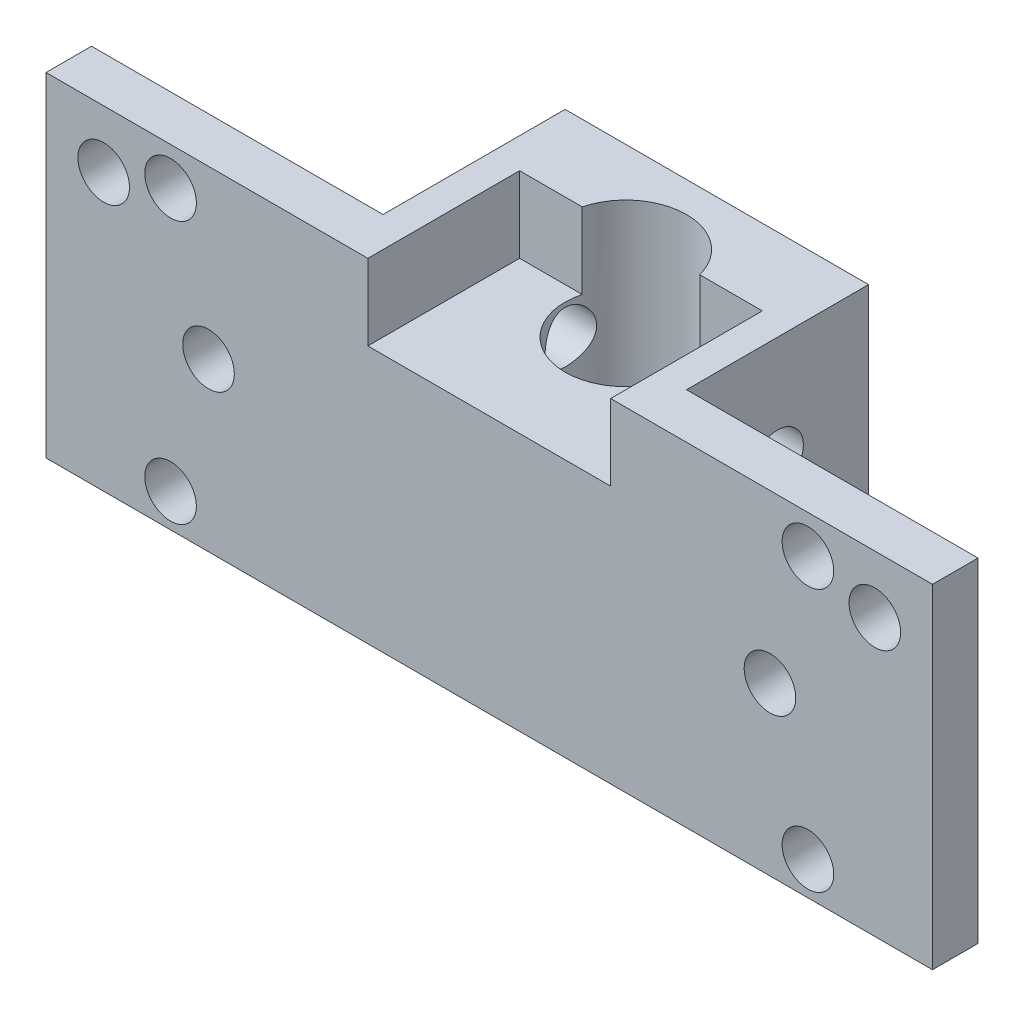
from build123d import *

# Parameters (mm, degrees)
ESQUISSE1_W             = 20
ESQUISSE1_H             = 22
BOSS_EXTRU_1_DEPTH      = 12
ESQUISSE2_R             = 4
ENL_V_MAT_EXTRU_1_DEPTH = 26
ESQUISSE4_W             = 58.42
ESQUISSE4_H             = 22
ESQUISSE4_R             = 1.7
BOSS_EXTRU_2_DEPTH      = 3
ESQUISSE5_R             = 1.7
ENL_V_MAT_EXTRU_2_DEPTH = 3
ESQUISSE3_R             = 1.7
ENL_V_MAT_EXTRU_3_DEPTH = 27
ESQUISSE6_W             = 16
ESQUISSE6_H             = 5
ENL_V_MAT_EXTRU_4_DEPTH = 10


with BuildPart() as part:
    # Esquisse1 → Boss.-Extru.1 (new body)
    with BuildSketch(Plane.XY):
        with Locations((10, 11)):
            Rectangle(ESQUISSE1_W, ESQUISSE1_H)
    extrude(amount=BOSS_EXTRU_1_DEPTH)

    # Esquisse2 → Enlèv. mat.-Extru.1 (cut)
    with BuildSketch(Plane(origin=(0, 22, 0), x_dir=(1, 0, 0), z_dir=(0, 1, 0))):
        with Locations((10, -6)):
            Circle(ESQUISSE2_R)
    extrude(amount=-ENL_V_MAT_EXTRU_1_DEPTH, mode=Mode.SUBTRACT)

    # Esquisse4 → Boss.-Extru.2 (add)
    with BuildSketch(Plane.XY.offset(12)):
        with Locations((10, 11)):
            Rectangle(ESQUISSE4_W, ESQUISSE4_H)
        with Locations((-15.41, 18.2)):
            Circle(ESQUISSE4_R, mode=Mode.SUBTRACT)
        with Locations((35.41, 18.2)):
            Circle(ESQUISSE4_R, mode=Mode.SUBTRACT)
    extrude(amount=BOSS_EXTRU_2_DEPTH)

    # Esquisse5 → Enlèv. mat.-Extru.2 (cut)
    with BuildSketch(Plane.XY.offset(15)):
        with Locations((-11, 19.5)):
            Circle(ESQUISSE5_R)
        with Locations((-11, 2.2)):
            Circle(ESQUISSE5_R)
        with Locations((31, 2.2)):
            Circle(ESQUISSE5_R)
        with Locations((31, 19.5)):
            Circle(ESQUISSE5_R)
        with Locations((-8.5, 11)):
            Circle(ESQUISSE5_R)
        with Locations((28.5, 11)):
            Circle(ESQUISSE5_R)
    extrude(amount=-ENL_V_MAT_EXTRU_2_DEPTH, mode=Mode.SUBTRACT)

    # Esquisse3 → Enlèv. mat.-Extru.3 (cut)
    with BuildSketch(Plane(origin=(20, 0, 0), x_dir=(0, 0, -1), z_dir=(1, 0, 0))):
        with Locations((-6, 15)):
            Circle(ESQUISSE3_R)
        with Locations((-6, 7)):
            Circle(ESQUISSE3_R)
    extrude(amount=-ENL_V_MAT_EXTRU_3_DEPTH, mode=Mode.SUBTRACT)

    # Esquisse6 → Enlèv. mat.-Extru.4 (cut)
    with BuildSketch(Plane.XY.offset(15)):
        with Locations((10, 19.5)):
            Rectangle(ESQUISSE6_W, ESQUISSE6_H)
    extrude(amount=-ENL_V_MAT_EXTRU_4_DEPTH, mode=Mode.SUBTRACT)


solid = part.part
